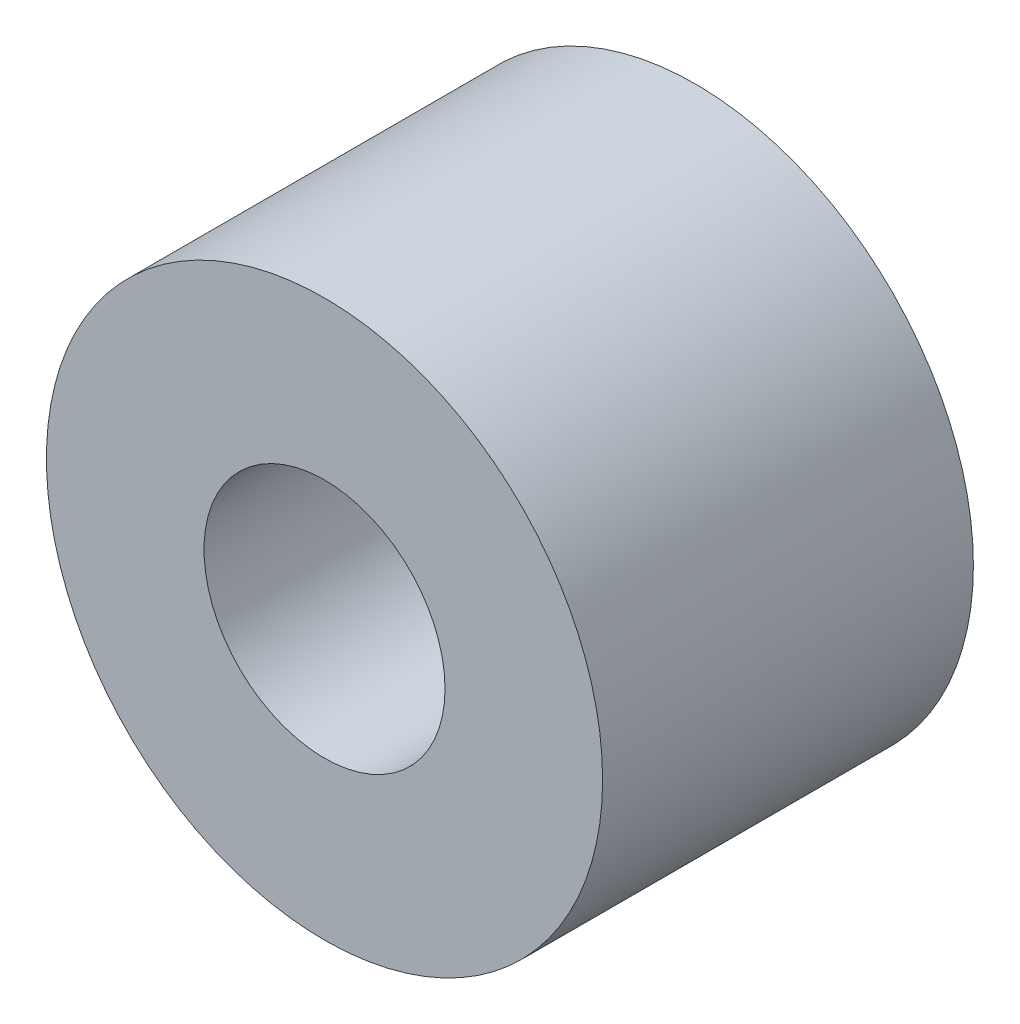
from build123d import *

# Parameters (mm, degrees)
SKETCH3_R                = 9.525
SKETCH3_R_2              = 4.1275
BOSS_EXTRUDE1_DEPTH      = 6.35
BOSS_EXTRUDE1_DEPTH_BACK = 6.35


with BuildPart() as part:
    # Sketch3 → Boss-Extrude1 (new body, two sides)
    with BuildSketch(Plane.XY) as boss_extrude1_sk:
        Circle(SKETCH3_R)
        Circle(SKETCH3_R_2, mode=Mode.SUBTRACT)
    extrude(amount=BOSS_EXTRUDE1_DEPTH)
    extrude(boss_extrude1_sk.sketch, amount=-BOSS_EXTRUDE1_DEPTH_BACK)


solid = part.part
